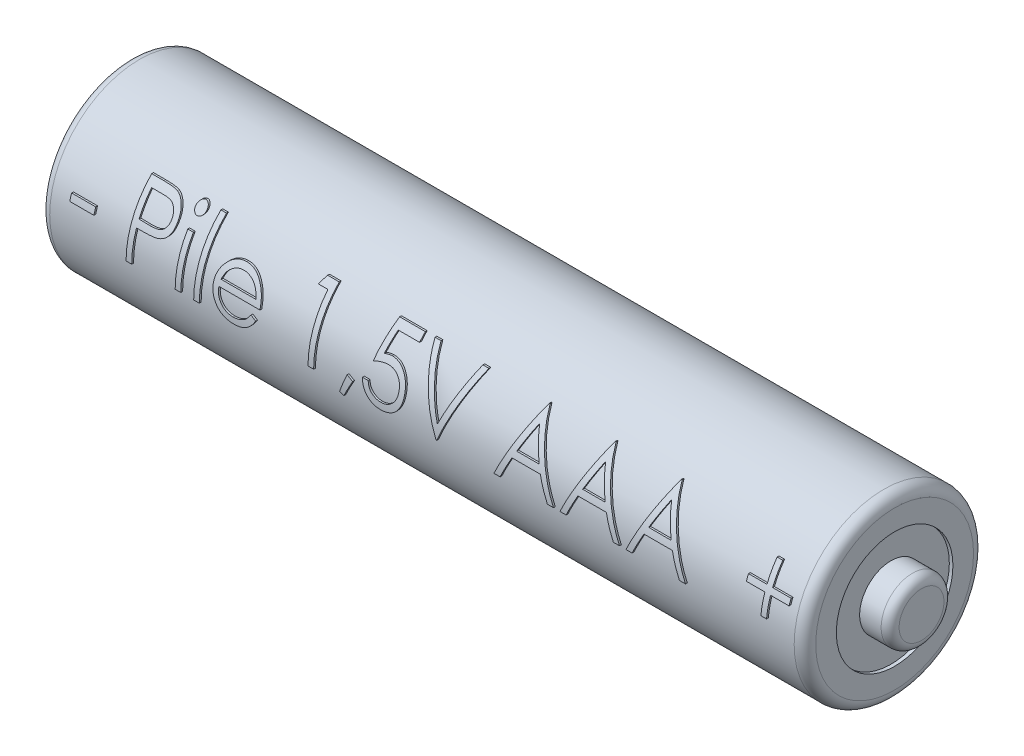
from build123d import *

# Parameters (mm, degrees)
EXTRUSION1_REACH      = 46.565
EXTRUSION1_END_RADIUS = 5
ESQUISSE2_W           = 1.346153846
ESQUISSE2_H           = 0.358974359
ESQUISSE2_W_2         = 0.314102564
ESQUISSE2_H_2         = 2.557692308
ESQUISSE2_H_3         = 3.58974359


with BuildPart() as part:
    # Esquisse1 → Révolution1 (revolve)
    with BuildSketch(Plane.XY, mode=Mode.PRIVATE) as r_volution1_sk:
        with BuildLine():
            Line((0, 0), (0, 4))
            Line((0, 4), (-0.1, 4))
            Line((-0.1, 4), (-0.1, 4.5))
            ThreePointArc((-0.1, 4.5), (0.046446609, 4.853553391), (0.4, 5))
            Line((0.4, 5), (41.9, 5))
            ThreePointArc((41.9, 5), (42.324264069, 4.824264069), (42.5, 4.4))
            Line((42.5, 4.4), (42.5, 3.25))
            Line((42.5, 3.25), (42.3, 3.25))
            Line((42.3, 3.25), (42.3, 1.75))
            Line((42.3, 1.75), (43.5, 1.75))
            ThreePointArc((43.5, 1.75), (43.853553391, 1.603553391), (44, 1.25))
            Line((44, 1.25), (44, 0))
            Line((44, 0), (0, 0))
        make_face()
    revolve(r_volution1_sk.sketch.rotate(Axis((44, 0, 0), (-1, 0, 0)), 90), axis=Axis((44, 0, 0), (-1, 0, 0)))

    # Extrusion1: up to this cylinder (the profile starts inside it)
    extrusion1_end = Plane(origin=(21.213141, 0, 0.1), z_dir=(1, 0, 0)) * Cylinder(EXTRUSION1_END_RADIUS, 142.24859, mode=Mode.PRIVATE)
    # Esquisse2 → Extrusion1 (add, up to the surface)
    with BuildSketch(Plane.XY, mode=Mode.PRIVATE) as extrusion1_sk1:
        with Locations((2.153846154, 1.346153847)):
            Rectangle(ESQUISSE2_W, ESQUISSE2_H)
    extrusion1_tool1 = extrude(extrusion1_sk1.sketch, amount=EXTRUSION1_REACH, mode=Mode.PRIVATE) & extrusion1_end
    add(extrusion1_tool1.solids().sort_by_distance((2.153846, 1.346154, 0))[0])
    # Esquisse2 → Extrusion1 (add, up to the surface)
    with BuildSketch(Plane.XY, mode=Mode.PRIVATE) as extrusion1_sk2:
        with BuildLine():
            Line((4.756410256, 3.5), (5.442808494, 3.5))
            add(Edge.make_bspline(
                [(5.442808494, 3.5), (5.4900194, 3.499948104), (5.580477593, 3.499848668), (5.710192648, 3.496833922), (5.82800238, 3.49280723), (5.933652761, 3.487225337), (6.027468859, 3.480628747), (6.109026158, 3.471376708), (6.178965715, 3.461716412), (6.220872164, 3.451895005), (6.239983974, 3.447415865)],
                knots=[0, 0, 0, 0, 1.415646017, 2.712440637, 3.8905458, 4.950247383, 5.884950622, 6.709939814, 7.411656543, 8, 8, 8, 8], degree=3))
            add(Edge.make_bspline(
                [(6.239983974, 3.447415865), (6.264177508, 3.440793916), (6.311994485, 3.427706054), (6.380895528, 3.40149233), (6.446449374, 3.370410165), (6.508880932, 3.334986225), (6.567423015, 3.293700661), (6.622949056, 3.248227043), (6.674969037, 3.197515475), (6.723190429, 3.142134735), (6.767475226, 3.083014525), (6.805604909, 3.019272295), (6.837532136, 2.951980992), (6.864915407, 2.881187421), (6.884623862, 2.806297097), (6.899470762, 2.727830385), (6.908894389, 2.645795695), (6.909796951, 2.589735827), (6.91025641, 2.561197917)],
                knots=[0, 0, 0, 0, 0.999701418, 1.975846123, 2.934577507, 3.890451536, 4.834027766, 5.787354733, 6.749476667, 7.726910423, 8.712836071, 9.690891519, 10.682875813, 11.679750201, 12.712814741, 13.765529915, 14.8625177, 16, 16, 16, 16], degree=3))
            add(Edge.make_bspline(
                [(6.91025641, 2.561197917), (6.909834986, 2.53242014), (6.90901044, 2.476114476), (6.899114154, 2.393741688), (6.885783963, 2.315023298), (6.86528691, 2.240133847), (6.838441237, 2.169518077), (6.806949184, 2.102096845), (6.768965654, 2.039017173), (6.725320824, 1.980050055), (6.67676923, 1.925140143), (6.623516292, 1.874685348), (6.565776999, 1.82898101), (6.503734851, 1.787924666), (6.436785002, 1.752468387), (6.365942849, 1.720711082), (6.290592632, 1.694040021), (6.238450118, 1.68000996), (6.211939103, 1.672876603)],
                knots=[0, 0, 0, 0, 1.121902311, 2.195077645, 3.232258892, 4.234102512, 5.217864754, 6.176164875, 7.132989551, 8.084763148, 9.034132444, 9.988522005, 10.94243251, 11.903244335, 12.886203696, 13.894208494, 14.929344452, 16, 16, 16, 16], degree=3))
            add(Edge.make_bspline(
                [(6.211939103, 1.672876603), (6.190011769, 1.668213621), (6.141956741, 1.657994427), (6.062814019, 1.64658597), (5.970668633, 1.63684837), (5.865646353, 1.629547232), (5.747841448, 1.623296864), (5.617190191, 1.61832877), (5.473436114, 1.615598916), (5.37316487, 1.615458123), (5.320813301, 1.615384615)],
                knots=[0, 0, 0, 0, 0.601384939, 1.31797006, 2.144135048, 3.087295005, 4.142315834, 5.309527816, 6.595305764, 8, 8, 8, 8], degree=3))
            Line((5.320813301, 1.615384615), (5.070512821, 1.615384615))
            Line((5.070512821, 1.615384615), (5.070512821, 0))
            Line((5.070512821, 0), (4.756410256, 0))
            Line((4.756410256, 0), (4.756410256, 3.5))
        make_face()
        with BuildLine():
            Line((5.070512821, 3.141025641), (5.070512821, 1.974358974))
            Line((5.070512821, 1.974358974), (5.683293269, 1.966646635))
            add(Edge.make_bspline(
                [(5.683293269, 1.966646635), (5.713213195, 1.966631171), (5.770972995, 1.966601319), (5.854409218, 1.970586542), (5.931818506, 1.975187075), (6.002963081, 1.981922998), (6.067875015, 1.991444256), (6.126662544, 2.001055994), (6.178869827, 2.014961356), (6.239969029, 2.033684426), (6.308052376, 2.065617041), (6.382119925, 2.111966931), (6.444890511, 2.17104764), (6.499208808, 2.237475471), (6.542314686, 2.3113746), (6.573870678, 2.390443537), (6.592411836, 2.473871387), (6.594898029, 2.530959525), (6.596153846, 2.559795673)],
                knots=[0, 0, 0, 0, 1.160613943, 2.240541288, 3.23993089, 4.169200891, 5.011653406, 5.7853311, 6.478053781, 7.106038997, 8.262395093, 9.384106736, 10.481365981, 11.59014053, 12.70357646, 13.786202915, 14.881775077, 16, 16, 16, 16], degree=3))
            add(Edge.make_bspline(
                [(6.596153846, 2.559795673), (6.5948912, 2.587934187), (6.592381215, 2.643870069), (6.573725352, 2.725848829), (6.542376038, 2.804084534), (6.498919443, 2.877057619), (6.446178313, 2.943246423), (6.38487897, 3.00074355), (6.315165709, 3.046965253), (6.250317478, 3.076798534), (6.192716292, 3.09501381), (6.142684332, 3.10775865), (6.086193657, 3.117934257), (6.023225878, 3.126173759), (5.954269044, 3.133227221), (5.878730729, 3.138013198), (5.796897086, 3.140814654), (5.740086515, 3.140953609), (5.710637019, 3.141025641)],
                knots=[0, 0, 0, 0, 1.120700087, 2.227813068, 3.331159281, 4.466773991, 5.599788987, 6.693661531, 7.80175334, 8.91857717, 9.525282508, 10.207424825, 10.974604443, 11.810962634, 12.737642355, 13.736264703, 14.826523623, 16, 16, 16, 16], degree=3))
            Line((5.710637019, 3.141025641), (5.070512821, 3.141025641))
        make_face(mode=Mode.SUBTRACT)
    extrusion1_tool2 = extrude(extrusion1_sk2.sketch, amount=EXTRUSION1_REACH, mode=Mode.PRIVATE) & extrusion1_end
    add(extrusion1_tool2.solids().sort_by_distance((5.099609, 3.458904, 0))[0])
    # Esquisse2 → Extrusion1 (add, up to the surface)
    with BuildSketch(Plane.XY, mode=Mode.PRIVATE) as extrusion1_sk3:
        with BuildLine():
            add(Edge.make_bspline(
                [(7.649238782, 3.634615385), (7.668730098, 3.633711232), (7.706897838, 3.631940728), (7.762091105, 3.616779251), (7.812348117, 3.591079566), (7.85692585, 3.556599885), (7.895177737, 3.516050441), (7.921958447, 3.468789473), (7.939170843, 3.417730834), (7.941249399, 3.382115745), (7.942307692, 3.363982372)],
                knots=[0, 0, 0, 0, 1.055194115, 2.066272739, 3.074728998, 4.095836921, 5.109056067, 6.073838105, 7.019297344, 8, 8, 8, 8], degree=3))
            add(Edge.make_bspline(
                [(7.942307692, 3.363982372), (7.941225532, 3.346319719), (7.939086231, 3.311402744), (7.921971742, 3.261229272), (7.894949504, 3.214624988), (7.856950379, 3.174154278), (7.812341618, 3.139693658), (7.762092832, 3.113988919), (7.706897383, 3.098828782), (7.668729944, 3.097058093), (7.649238782, 3.096153846)],
                knots=[0, 0, 0, 0, 0.96129708, 1.900370562, 2.859976407, 3.87933698, 4.906634145, 5.921202961, 6.938410037, 8, 8, 8, 8], degree=3))
            add(Edge.make_bspline(
                [(7.649238782, 3.096153846), (7.629970507, 3.097023566), (7.592467327, 3.098716363), (7.538100484, 3.114286381), (7.488271995, 3.139702454), (7.443607322, 3.173928639), (7.406377129, 3.214873536), (7.379278804, 3.26120083), (7.362203842, 3.311409985), (7.360059213, 3.346322151), (7.358974359, 3.363982372)],
                knots=[0, 0, 0, 0, 1.054934014, 2.053291228, 3.073705704, 4.106921865, 5.123545215, 6.088680038, 7.033164197, 8, 8, 8, 8], degree=3))
            add(Edge.make_bspline(
                [(7.358974359, 3.363982372), (7.360035446, 3.382113221), (7.362119487, 3.417723354), (7.379291603, 3.468818387), (7.406151411, 3.515799889), (7.443631974, 3.556825388), (7.488265434, 3.591070823), (7.53810218, 3.616481804), (7.592466879, 3.632053144), (7.629970355, 3.633745758), (7.649238782, 3.634615385)],
                knots=[0, 0, 0, 0, 0.98631895, 1.937192651, 2.907499808, 3.917963147, 4.944918757, 5.95915025, 6.951458133, 8, 8, 8, 8], degree=3))
        make_face()
    extrusion1_tool3 = extrude(extrusion1_sk3.sketch, amount=EXTRUSION1_REACH, mode=Mode.PRIVATE) & extrusion1_end
    add(extrusion1_tool3.solids().sort_by_distance((7.650547, 3.365366, 0))[0])
    # Esquisse2 → Extrusion1 (add, up to the surface)
    with BuildSketch(Plane.XY, mode=Mode.PRIVATE) as extrusion1_sk4:
        with Locations((7.650641026, 1.278846154)):
            Rectangle(ESQUISSE2_W_2, ESQUISSE2_H_2)
    extrusion1_tool4 = extrude(extrusion1_sk4.sketch, amount=EXTRUSION1_REACH, mode=Mode.PRIVATE) & extrusion1_end
    add(extrusion1_tool4.solids().sort_by_distance((7.650641, 1.278846, 0))[0])
    # Esquisse2 → Extrusion1 (add, up to the surface)
    with BuildSketch(Plane.XY, mode=Mode.PRIVATE) as extrusion1_sk5:
        with Locations((8.682692308, 1.794871795)):
            Rectangle(ESQUISSE2_W_2, ESQUISSE2_H_3)
    extrusion1_tool5 = extrude(extrusion1_sk5.sketch, amount=EXTRUSION1_REACH, mode=Mode.PRIVATE) & extrusion1_end
    add(extrusion1_tool5.solids().sort_by_distance((8.682692, 1.794872, 0))[0])
    # Esquisse2 → Extrusion1 (add, up to the surface)
    with BuildSketch(Plane.XY, mode=Mode.PRIVATE) as extrusion1_sk6:
        with BuildLine():
            Line((11.656850962, 0.807692308), (11.935897436, 0.661157853))
            add(Edge.make_bspline(
                [(11.935897436, 0.661157853), (11.913660841, 0.621714521), (11.870397232, 0.544973418), (11.795996484, 0.439541558), (11.718004412, 0.344693842), (11.632900444, 0.262964188), (11.543230765, 0.191712803), (11.44849811, 0.129374978), (11.348209292, 0.076256458), (11.242359567, 0.03150393), (11.130060016, -0.002905564), (11.0110385, -0.027209785), (10.885067005, -0.042233054), (10.798720825, -0.043978194), (10.754507212, -0.044871795)],
                knots=[0, 0, 0, 0, 1.120438281, 2.179929193, 3.190490725, 4.156257408, 5.095198341, 6.022838206, 6.959905092, 7.901321166, 8.864066838, 9.862729781, 10.905609505, 12, 12, 12, 12], degree=3))
            add(Edge.make_bspline(
                [(10.754507212, -0.044871795), (10.705365234, -0.04372462), (10.609503472, -0.041486813), (10.469963725, -0.022194348), (10.338584307, 0.00927801), (10.215372603, 0.053243552), (10.100630351, 0.110670876), (9.994129496, 0.180630358), (9.89530997, 0.262762612), (9.807285761, 0.357779056), (9.728041878, 0.459461013), (9.658116058, 0.565416898), (9.599658627, 0.675380122), (9.552106017, 0.788650646), (9.513701152, 0.90451454), (9.486934448, 1.024026007), (9.4715047, 1.146861592), (9.469140255, 1.229958927), (9.467948718, 1.271834936)],
                knots=[0, 0, 0, 0, 1.145258523, 2.234067595, 3.276747158, 4.290159414, 5.277019952, 6.260822364, 7.254936242, 8.264827045, 9.274100331, 10.257902744, 11.220704747, 12.172965371, 13.118907548, 14.062713208, 15.023725156, 16, 16, 16, 16], degree=3))
            add(Edge.make_bspline(
                [(9.467948718, 1.271834936), (9.469007859, 1.311129766), (9.471106938, 1.389006931), (9.484337725, 1.504272476), (9.507786018, 1.616300928), (9.539962342, 1.725185376), (9.581513588, 1.83074351), (9.632345807, 1.933039574), (9.692538185, 2.031964713), (9.739010859, 2.094367847), (9.762419872, 2.125801282)],
                knots=[0, 0, 0, 0, 1.024358464, 2.0301432, 3.019427413, 4.004406732, 4.986367066, 5.972626655, 6.978780325, 8, 8, 8, 8], degree=3))
            add(Edge.make_bspline(
                [(9.762419872, 2.125801282), (9.794127555, 2.163670152), (9.856538501, 2.238208303), (9.962094857, 2.336146628), (10.076395053, 2.418190404), (10.198006679, 2.48619754), (10.328343153, 2.537871187), (10.465652444, 2.576378769), (10.61149803, 2.59795678), (10.711203251, 2.601004614), (10.762219551, 2.602564103)],
                knots=[0, 0, 0, 0, 1.030682036, 2.02871468, 2.997146059, 3.962720338, 4.930598197, 5.918074684, 6.934738563, 8, 8, 8, 8], degree=3))
            add(Edge.make_bspline(
                [(10.762219551, 2.602564103), (10.814667157, 2.601210054), (10.917557403, 2.598553718), (11.067589524, 2.573927385), (11.20955024, 2.53487483), (11.343382744, 2.47972104), (11.469100605, 2.408561488), (11.585886655, 2.320419647), (11.695738167, 2.218001559), (11.759646746, 2.13923835), (11.792167468, 2.099158654)],
                knots=[0, 0, 0, 0, 1.056321875, 2.072262726, 3.055038591, 4.01806755, 4.982017516, 5.957941055, 6.960871419, 8, 8, 8, 8], degree=3))
            add(Edge.make_bspline(
                [(11.792167468, 2.099158654), (11.814294406, 2.068955072), (11.858400999, 2.008748954), (11.913648099, 1.910577797), (11.961605494, 1.807867202), (11.999938455, 1.698956905), (12.030977957, 1.585137325), (12.053434775, 1.46559478), (12.066604394, 1.340364869), (12.069193091, 1.255038314), (12.070512821, 1.211538462)],
                knots=[0, 0, 0, 0, 0.94817472, 1.890038105, 2.849395472, 3.817997239, 4.812318967, 5.836947057, 6.897266129, 8, 8, 8, 8], degree=3))
            Line((12.070512821, 1.211538462), (9.782051282, 1.211538462))
            add(Edge.make_bspline(
                [(9.782051282, 1.211538462), (9.783590888, 1.177837997), (9.786618462, 1.111567394), (9.800733606, 1.01459661), (9.822982379, 0.922223268), (9.854251442, 0.835140226), (9.892118287, 0.752210099), (9.938504004, 0.674048062), (9.993843558, 0.601010132), (10.055569257, 0.532442994), (10.124276353, 0.471382233), (10.1965591, 0.416730457), (10.273452665, 0.37092486), (10.354350748, 0.33374497), (10.439122534, 0.304638654), (10.527794729, 0.284770834), (10.620192845, 0.271463727), (10.683178579, 0.269984061), (10.715244391, 0.269230769)],
                knots=[0, 0, 0, 0, 1.094153842, 2.151609401, 3.174256925, 4.172055639, 5.149267565, 6.128595816, 7.11444997, 8.118368179, 9.117203808, 10.09244225, 11.054858984, 12.015122123, 12.976791628, 13.957293641, 14.960065497, 16, 16, 16, 16], degree=3))
            add(Edge.make_bspline(
                [(10.715244391, 0.269230769), (10.746595539, 0.269838826), (10.80880223, 0.271045327), (10.901443087, 0.282777238), (10.992582614, 0.301747513), (11.081843598, 0.327637504), (11.167414443, 0.359214356), (11.246659994, 0.397317213), (11.319540209, 0.43946696), (11.387657176, 0.487676635), (11.453728169, 0.546684822), (11.519270656, 0.620320543), (11.589547309, 0.707408071), (11.633536902, 0.772953737), (11.656850962, 0.807692308)],
                knots=[0, 0, 0, 0, 0.99110716, 1.966546729, 2.947904876, 3.932708344, 4.903319531, 5.828989031, 6.710028674, 7.56322171, 8.463672341, 9.504779593, 10.677557249, 12, 12, 12, 12], degree=3))
        make_face()
        with BuildLine():
            add(Edge.make_bspline(
                [(11.756410256, 1.525641026), (11.744913632, 1.567303899), (11.72278633, 1.64749152), (11.676549966, 1.75853241), (11.624478425, 1.857220311), (11.562856694, 1.942799944), (11.493037968, 2.018803457), (11.412392786, 2.085222043), (11.321956892, 2.144639494), (11.222197751, 2.194791993), (11.116555966, 2.237481852), (11.005949774, 2.266106968), (10.893091986, 2.28571651), (10.8167577, 2.287542618), (10.778345353, 2.288461538)],
                knots=[0, 0, 0, 0, 1.154881502, 2.222775134, 3.210006277, 4.132804581, 5.035138423, 5.962687519, 6.919655026, 7.923214229, 8.944639381, 9.960483929, 10.97369054, 12, 12, 12, 12], degree=3))
            add(Edge.make_bspline(
                [(10.778345353, 2.288461538), (10.746995914, 2.287849867), (10.685024665, 2.286640721), (10.593723597, 2.275170592), (10.506043898, 2.256210747), (10.42133861, 2.23024579), (10.340717742, 2.195637188), (10.262522974, 2.155053961), (10.188742577, 2.105512377), (10.142601282, 2.067753522), (10.119290865, 2.048677885)],
                knots=[0, 0, 0, 0, 1.04873581, 2.073130211, 3.073294108, 4.04793562, 5.032784715, 6.005352987, 6.992311501, 8, 8, 8, 8], degree=3))
            add(Edge.make_bspline(
                [(10.119290865, 2.048677885), (10.102597583, 2.033583569), (10.068814449, 2.003036353), (10.023673928, 1.950407146), (9.980453455, 1.893655584), (9.941119802, 1.83061046), (9.905042216, 1.761989681), (9.871282239, 1.688372045), (9.840895827, 1.609198915), (9.823799717, 1.554026476), (9.815004006, 1.525641026)],
                knots=[0, 0, 0, 0, 0.879870761, 1.780643979, 2.707998968, 3.669668524, 4.684282772, 5.740141944, 6.837334558, 8, 8, 8, 8], degree=3))
            Line((9.815004006, 1.525641026), (11.756410256, 1.525641026))
        make_face(mode=Mode.SUBTRACT)
    extrusion1_tool6 = extrude(extrusion1_sk6.sketch, amount=EXTRUSION1_REACH, mode=Mode.PRIVATE) & extrusion1_end
    add(extrusion1_tool6.solids().sort_by_distance((10.701836, 1.307056, 0))[0])
    # Esquisse2 → Extrusion1 (add, up to the surface)
    with BuildSketch(Plane.XY, mode=Mode.PRIVATE) as extrusion1_sk7:
        Polygon((14.564403045, 3.5), (15.211538462, 3.5), (15.211538462, 0), (14.897435897, 0), (14.897435897, 3.141025641), (14.358974359, 3.141025641), align=None)
    extrusion1_tool7 = extrude(extrusion1_sk7.sketch, amount=EXTRUSION1_REACH, mode=Mode.PRIVATE) & extrusion1_end
    add(extrusion1_tool7.solids().sort_by_distance((15.007283, 1.943869, 0))[0])
    # Esquisse2 → Extrusion1 (add, up to the surface)
    with BuildSketch(Plane.XY, mode=Mode.PRIVATE) as extrusion1_sk8:
        Polygon((17.044270833, 0.628205128), (17.365384615, 0.47255609), (16.883012821, -0.448717949), (16.647435897, -0.346354167), align=None)
    extrusion1_tool8 = extrude(extrusion1_sk8.sketch, amount=EXTRUSION1_REACH, mode=Mode.PRIVATE) & extrusion1_end
    add(extrusion1_tool8.solids().sort_by_distance((16.996694, 0.102302, 0))[0])
    # Esquisse2 → Extrusion1 (add, up to the surface)
    with BuildSketch(Plane.XY, mode=Mode.PRIVATE) as extrusion1_sk9:
        with BuildLine():
            Line((20.012820513, 3.5), (20.012820513, 3.141025641))
            Line((20.012820513, 3.141025641), (18.822315705, 3.141025641))
            Line((18.822315705, 3.141025641), (18.633713942, 2.220452724))
            add(Edge.make_bspline(
                [(18.633713942, 2.220452724), (18.670769817, 2.230682996), (18.742559713, 2.25050253), (18.848519573, 2.2725083), (18.949111777, 2.285773744), (19.014387147, 2.287585055), (19.045973558, 2.288461538)],
                knots=[0, 0, 0, 0, 1.100273476, 2.13160584, 3.095893838, 4, 4, 4, 4], degree=3))
            add(Edge.make_bspline(
                [(19.045973558, 2.288461538), (19.085057297, 2.287615603), (19.161905695, 2.285952282), (19.274344642, 2.269980432), (19.381677535, 2.244840518), (19.483679905, 2.209719996), (19.580540456, 2.164810263), (19.671368017, 2.108710322), (19.75752593, 2.043176991), (19.837468524, 1.967831979), (19.909992832, 1.884910363), (19.973758822, 1.795752492), (20.027921412, 1.701224829), (20.071482167, 1.600424221), (20.106266501, 1.494465067), (20.129418496, 1.382232485), (20.144835205, 1.264784365), (20.146557592, 1.184479795), (20.147435897, 1.143529647)],
                knots=[0, 0, 0, 0, 1.052922333, 2.070308379, 3.05430497, 4.020497103, 4.973039431, 5.925935799, 6.892292201, 7.88610001, 8.88166317, 9.857072816, 10.836096531, 11.812156883, 12.81219415, 13.836441305, 14.89672472, 16, 16, 16, 16], degree=3))
            add(Edge.make_bspline(
                [(20.147435897, 1.143529647), (20.146770822, 1.115007427), (20.14544966, 1.05834844), (20.138731072, 0.974204239), (20.125795356, 0.891841406), (20.108427632, 0.811249014), (20.085885214, 0.732579642), (20.05859616, 0.655608114), (20.025200132, 0.580813507), (19.988568757, 0.507488112), (19.947322279, 0.437289605), (19.901543772, 0.371640618), (19.85317828, 0.309556337), (19.801136895, 0.251702604), (19.7449359, 0.198459586), (19.685255933, 0.149511304), (19.622573214, 0.104029974), (19.555917972, 0.063861779), (19.486775489, 0.026898823), (19.414147272, -0.003424715), (19.339686571, -0.030535243), (19.262321696, -0.05214477), (19.182227883, -0.069077325), (19.099273107, -0.080577925), (19.013892437, -0.088954363), (18.956017425, -0.08947872), (18.926782853, -0.08974359)],
                knots=[0, 0, 0, 0, 1.056347294, 2.098418968, 3.122841568, 4.141288669, 5.149314143, 6.15115421, 7.162517403, 8.180376062, 9.185164535, 10.17417709, 11.141909838, 12.097768115, 13.052685741, 14.0056014, 14.954263652, 15.917497458, 16.885230207, 17.854509472, 18.828990115, 19.81800267, 20.826176721, 21.857883937, 22.917946725, 24, 24, 24, 24], degree=3))
            add(Edge.make_bspline(
                [(18.926782853, -0.08974359), (18.891908672, -0.089052752), (18.823297841, -0.08769361), (18.722777274, -0.073475124), (18.626062668, -0.053111208), (18.533932567, -0.022474938), (18.445561304, 0.015912357), (18.362138586, 0.064428528), (18.28153281, 0.119407632), (18.207020773, 0.184287985), (18.137864659, 0.255203667), (18.075958151, 0.332161308), (18.020824574, 0.41389075), (17.973346827, 0.500788904), (17.932848806, 0.592627435), (17.901033817, 0.689750436), (17.875355462, 0.79165044), (17.864492042, 0.86180395), (17.858974359, 0.897435897)],
                knots=[0, 0, 0, 0, 1.0467383, 2.05933395, 3.04377827, 4.011590433, 4.970194871, 5.932262533, 6.905835911, 7.896367577, 8.894135286, 9.877477877, 10.858688626, 11.851381753, 12.8477658, 13.868841284, 14.917554742, 16, 16, 16, 16], degree=3))
            Line((17.858974359, 0.897435897), (18.173076923, 0.897435897))
            add(Edge.make_bspline(
                [(18.173076923, 0.897435897), (18.18080548, 0.864059445), (18.195660197, 0.79990805), (18.228265946, 0.709776709), (18.268131821, 0.629457485), (18.31553617, 0.557887902), (18.3720862, 0.495478905), (18.436615629, 0.439861843), (18.508963352, 0.389686713), (18.589356582, 0.347863946), (18.674169661, 0.312195193), (18.762936871, 0.288443498), (18.853241217, 0.271742605), (18.914319588, 0.270070844), (18.945012019, 0.269230769)],
                knots=[0, 0, 0, 0, 1.136247022, 2.183929868, 3.172523383, 4.106158343, 5.02341133, 5.958108904, 6.928429099, 7.938127109, 8.96079061, 9.975095812, 10.982467395, 12, 12, 12, 12], degree=3))
            add(Edge.make_bspline(
                [(18.945012019, 0.269230769), (18.974970464, 0.270051547), (19.033958886, 0.271667666), (19.120770273, 0.284106678), (19.204583147, 0.303264249), (19.284570503, 0.331934104), (19.362132043, 0.366778822), (19.435305814, 0.411493898), (19.506208691, 0.462953917), (19.572636824, 0.521910547), (19.633476273, 0.586880241), (19.687232395, 0.656357635), (19.732009308, 0.730474481), (19.769743417, 0.807947634), (19.798396716, 0.889626191), (19.818837697, 0.975127366), (19.830840756, 1.064662347), (19.832491936, 1.125731656), (19.833333333, 1.156850962)],
                knots=[0, 0, 0, 0, 1.027316725, 2.022795036, 3.002884548, 3.971462791, 4.93288096, 5.914575861, 6.907176829, 7.935150275, 8.956128384, 9.956726525, 10.942570165, 11.921478529, 12.907843606, 13.90538589, 14.932640048, 16, 16, 16, 16], degree=3))
            add(Edge.make_bspline(
                [(19.833333333, 1.156850962), (19.832674854, 1.184926713), (19.831385974, 1.239881002), (19.820855404, 1.320280209), (19.802538431, 1.396353251), (19.777114551, 1.468467485), (19.744835044, 1.536690927), (19.705388731, 1.601093987), (19.658035333, 1.660827821), (19.603943445, 1.715920374), (19.544685404, 1.766765249), (19.479241661, 1.810109336), (19.408981734, 1.846573253), (19.334752135, 1.878041252), (19.254787236, 1.900641997), (19.170670604, 1.917609882), (19.081493896, 1.927425245), (19.020523208, 1.928787134), (18.989182692, 1.929487179)],
                knots=[0, 0, 0, 0, 1.045622112, 2.046656509, 3.013763289, 3.955457236, 4.890082067, 5.820317437, 6.762574623, 7.722996705, 8.69280354, 9.665887285, 10.63943826, 11.638615906, 12.663482002, 13.728887084, 14.832589034, 16, 16, 16, 16], degree=3))
            add(Edge.make_bspline(
                [(18.989182692, 1.929487179), (18.962053764, 1.928906588), (18.906039408, 1.927707815), (18.820116581, 1.918881318), (18.729824858, 1.904642024), (18.635510363, 1.885055776), (18.536889855, 1.859424699), (18.434171454, 1.828710199), (18.327139187, 1.7919882), (18.255021463, 1.764255986), (18.217948718, 1.75)],
                knots=[0, 0, 0, 0, 0.817624296, 1.688186739, 2.600797293, 3.572016777, 4.590301741, 5.671205678, 6.80286297, 8, 8, 8, 8], degree=3))
            Line((18.217948718, 1.75), (18.576923077, 3.5))
            Line((18.576923077, 3.5), (20.012820513, 3.5))
        make_face()
    extrusion1_tool9 = extrude(extrusion1_sk9.sketch, amount=EXTRUSION1_REACH, mode=Mode.PRIVATE) & extrusion1_end
    add(extrusion1_tool9.solids().sort_by_distance((19.970249, 3.320513, 0))[0])
    # Esquisse2 → Extrusion1 (add, up to the surface)
    with BuildSketch(Plane.XY, mode=Mode.PRIVATE) as extrusion1_sk10:
        Polygon((20.551282051, 3.5), (20.887820513, 3.5), (22.054487179, 0.741786859), (23.221153846, 3.5), (23.557692308, 3.5), (22.076923077, 0), (22.032051282, 0), align=None)
    extrusion1_tool10 = extrude(extrusion1_sk10.sketch, amount=EXTRUSION1_REACH, mode=Mode.PRIVATE) & extrusion1_end
    add(extrusion1_tool10.solids().sort_by_distance((20.719551, 3.453861, 0))[0])
    # Esquisse2 → Extrusion1 (add, up to the surface)
    with BuildSketch(Plane.XY, mode=Mode.PRIVATE) as extrusion1_sk11:
        Polygon((26.967948718, 3.5), (28.583333333, 0), (28.241887019, 0), (27.724459135, 1.121794872), (26.137820513, 1.121794872), (25.605669071, 0), (25.262820513, 0), (26.923076923, 3.5), align=None)
        Polygon((26.942007212, 2.817808494), (26.308193109, 1.480769231), (27.558994391, 1.480769231), align=None, mode=Mode.SUBTRACT)
    extrusion1_tool11 = extrude(extrusion1_sk11.sketch, amount=EXTRUSION1_REACH, mode=Mode.PRIVATE) & extrusion1_end
    add(extrusion1_tool11.solids().sort_by_distance((27.731837, 1.729783, 0))[0])
    # Esquisse2 → Extrusion1 (add, up to the surface)
    with BuildSketch(Plane.XY, mode=Mode.PRIVATE) as extrusion1_sk12:
        Polygon((30.647435897, 3.5), (32.262820513, 0), (31.921374199, 0), (31.403946314, 1.121794872), (29.817307692, 1.121794872), (29.28515625, 0), (28.942307692, 0), (30.602564103, 3.5), align=None)
        Polygon((30.621494391, 2.817808494), (29.987680288, 1.480769231), (31.238481571, 1.480769231), align=None, mode=Mode.SUBTRACT)
    extrusion1_tool12 = extrude(extrusion1_sk12.sketch, amount=EXTRUSION1_REACH, mode=Mode.PRIVATE) & extrusion1_end
    add(extrusion1_tool12.solids().sort_by_distance((31.411324, 1.729783, 0))[0])
    # Esquisse2 → Extrusion1 (add, up to the surface)
    with BuildSketch(Plane.XY, mode=Mode.PRIVATE) as extrusion1_sk13:
        Polygon((34.326923077, 3.5), (35.942307692, 0), (35.600861378, 0), (35.083433494, 1.121794872), (33.496794872, 1.121794872), (32.964643429, 0), (32.621794872, 0), (34.282051282, 3.5), align=None)
        Polygon((34.300981571, 2.817808494), (33.667167468, 1.480769231), (34.91796875, 1.480769231), align=None, mode=Mode.SUBTRACT)
    extrusion1_tool13 = extrude(extrusion1_sk13.sketch, amount=EXTRUSION1_REACH, mode=Mode.PRIVATE) & extrusion1_end
    add(extrusion1_tool13.solids().sort_by_distance((35.090811, 1.729783, 0))[0])
    # Esquisse2 → Extrusion1 (add, up to the surface)
    with BuildSketch(Plane.XY, mode=Mode.PRIVATE) as extrusion1_sk14:
        Polygon((40.115384615, 1.884615385), (40.115384615, 2.916666667), (40.429487179, 2.916666667), (40.429487179, 1.884615385), (41.461538462, 1.884615385), (41.461538462, 1.570512821), (40.429487179, 1.570512821), (40.429487179, 0.538461538), (40.115384615, 0.538461538), (40.115384615, 1.570512821), (39.083333333, 1.570512821), (39.083333333, 1.884615385), align=None)
    extrusion1_tool14 = extrude(extrusion1_sk14.sketch, amount=EXTRUSION1_REACH, mode=Mode.PRIVATE) & extrusion1_end
    add(extrusion1_tool14.solids().sort_by_distance((40.272436, 1.727564, 0))[0])


solid = part.part
